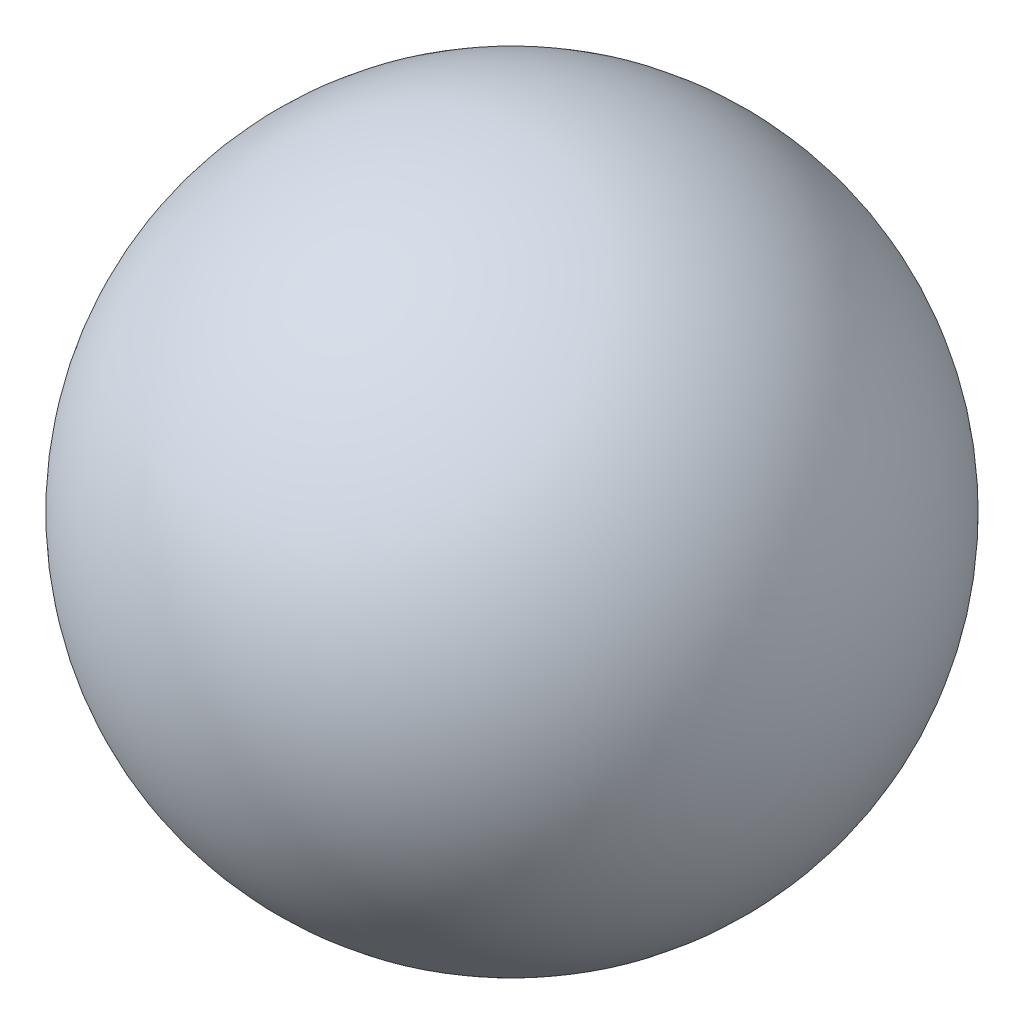
from build123d import *


with BuildPart() as part:
    # Эскиз1 → Повернуть1 (revolve)
    with BuildSketch(Plane(origin=(0, 0, 0), x_dir=(0, 0, -1), z_dir=(1, 0, 0))):
        with BuildLine():
            Line((0, 50), (0, -50))
            ThreePointArc((0, -50), (50, 0), (0, 50))
        make_face()
    revolve(axis=Axis((0, 50, 0), (0, -1, 0)))


solid = part.part
